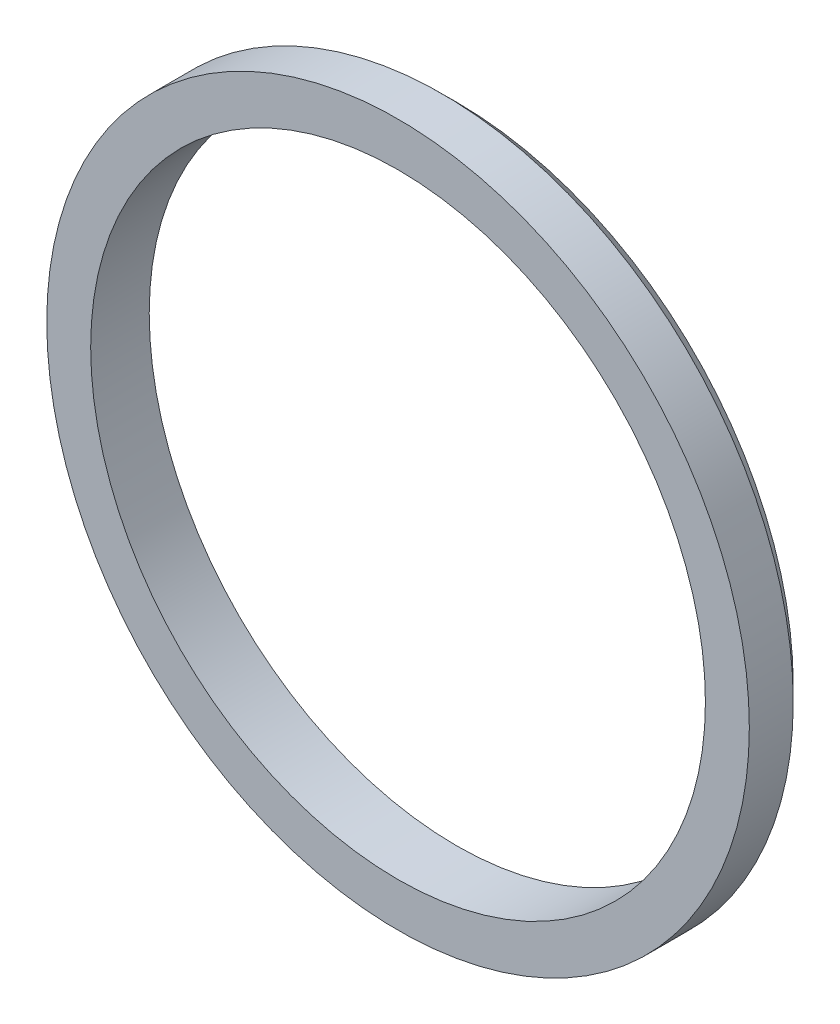
from build123d import *

# Parameters (mm, degrees)
ESQUISSE1_R        = 12
ESQUISSE1_R_2      = 10.5
BOSS_EXTRU_1_DEPTH = 1
CHANFREIN1_SIZE    = 0.5


with BuildPart() as part:
    # Esquisse1 → Boss.-Extru.1 (new body, symmetric)
    with BuildSketch(Plane.XY):
        Circle(ESQUISSE1_R)
        Circle(ESQUISSE1_R_2, mode=Mode.SUBTRACT)
    extrude(amount=BOSS_EXTRU_1_DEPTH, both=True)

    # Chanfrein1
    chanfrein1_edges = [part.edges().sort_by_distance(p)[0] for p in [
        (-12, 0, -1),
    ]]
    chamfer(chanfrein1_edges, length=CHANFREIN1_SIZE)


solid = part.part
